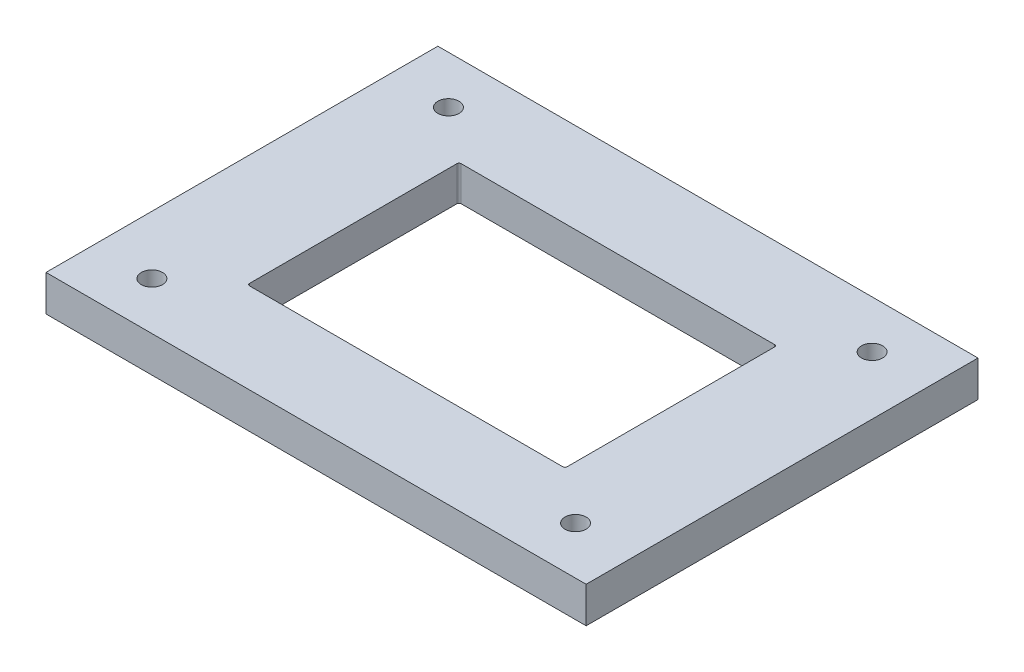
from build123d import *

# Parameters (mm, degrees)
SKETCH1_W           = 255
SKETCH1_H           = 185
BOSS_EXTRUDE1_DEPTH = 17
SKETCH2_W           = 149.94
SKETCH2_H           = 99.94
CUT_EXTRUDE1_DEPTH  = 19.5
CUT_EXTRUDE1_TAPER  = -2
FILLET1_R           = 1
SKETCH3_R           = 5
CUT_EXTRUDE2_DEPTH  = 19.5


with BuildPart() as part:
    # Sketch1 → Boss-Extrude1 (new body)
    with BuildSketch(Plane(origin=(0, 0, 0), x_dir=(1, 0, 0), z_dir=(0, 1, 0))):
        Rectangle(SKETCH1_W, SKETCH1_H)
    extrude(amount=-BOSS_EXTRUDE1_DEPTH)

    # Sketch2 → Cut-Extrude1 (cut)
    with BuildSketch(Plane(origin=(0, 0, 0), x_dir=(1, 0, 0), z_dir=(0, 1, 0))):
        Rectangle(SKETCH2_W, SKETCH2_H)
    extrude(amount=-CUT_EXTRUDE1_DEPTH, taper=CUT_EXTRUDE1_TAPER, mode=Mode.SUBTRACT)

    # Fillet1
    fillet1_edges = [part.edges().sort_by_distance(p)[0] for p in [
        (-75.266826541, -8.5, 50.266826541),
        (-75.266826541, -8.5, -50.266826541),
        (75.266826541, -8.5, -50.266826541),
        (75.266826541, -8.5, 50.266826541),
    ]]
    fillet(fillet1_edges, radius=FILLET1_R)

    # Sketch3 → Cut-Extrude2 (cut)
    with BuildSketch(Plane(origin=(0, 0, 0), x_dir=(1, 0, 0), z_dir=(0, 1, 0))):
        with Locations((-100, 70)):
            Circle(SKETCH3_R)
        with Locations((100, 70)):
            Circle(SKETCH3_R)
        with Locations((100, -70)):
            Circle(SKETCH3_R)
        with Locations((-100, -70)):
            Circle(SKETCH3_R)
    extrude(amount=-CUT_EXTRUDE2_DEPTH, mode=Mode.SUBTRACT)


solid = part.part
